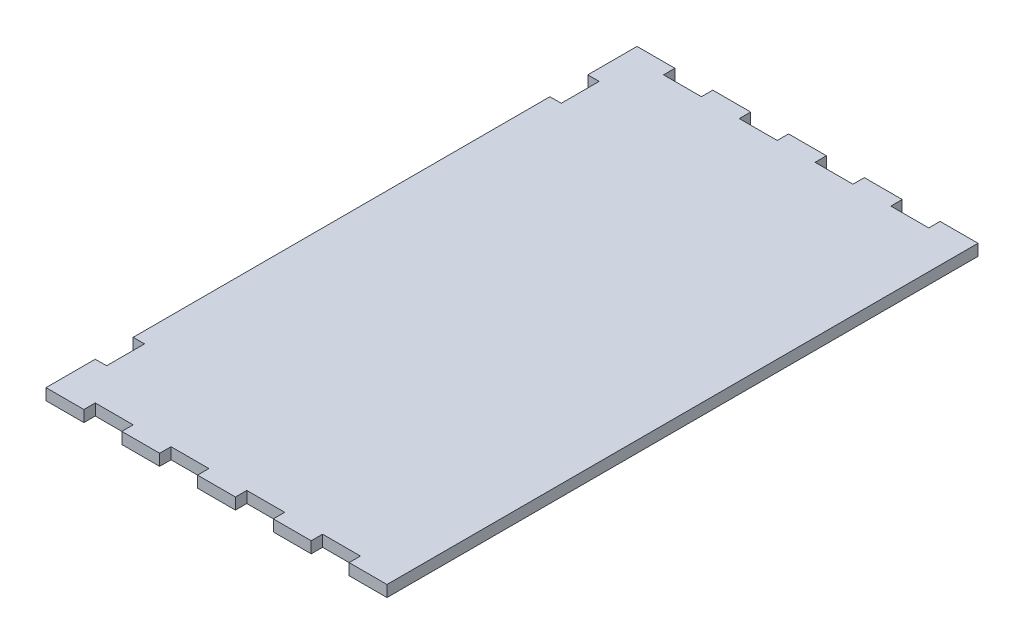
from build123d import *

# Parameters (mm, degrees)
BOSS_EXTRU_1_DEPTH = 3


with BuildPart() as part:
    # Esquisse1 → Boss.-Extru.1 (new body)
    with BuildSketch(Plane(origin=(0, 0, 0), x_dir=(1, 0, 0), z_dir=(0, 1, 0))):
        Polygon((-2.118354979, 8.128356032), (-2.118354979, 11.128356032), (-12.118354979, 11.128356032), (-12.118354979, 8.128356032), (-22.118354979, 8.128356032), (-22.118354979, 11.128356032), (-32.118354979, 11.128356032), (-32.118354979, -1.871643968), (-29.118354979, -1.871643968), (-29.118354979, -11.871643968), (-32.118354979, -11.871643968), (-32.118354979, -121.871643968), (-29.118354979, -121.871643968), (-29.118354979, -131.871643968), (-32.118354979, -131.871643968), (-32.118354979, -144.871643968), (-22.118354979, -144.871643968), (-22.118354979, -141.871643968), (-12.118354979, -141.871643968), (-12.118354979, -144.871643968), (-2.118354979, -144.871643968), (-2.118354979, -141.871643968), (7.881645021, -141.871643968), (7.881645021, -144.871643968), (17.881645021, -144.871643968), (17.881645021, -141.871643968), (27.881645021, -141.871643968), (27.881645021, -144.871643968), (37.881645021, -144.871643968), (37.881645021, -141.871643968), (47.881645021, -141.871643968), (47.881645021, -144.871643968), (57.881645021, -144.871643968), (57.881645021, 11.128356032), (47.881645021, 11.128356032), (47.881645021, 8.128356032), (37.881645021, 8.128356032), (37.881645021, 11.128356032), (27.881645021, 11.128356032), (27.881645021, 8.128356032), (17.881645021, 8.128356032), (17.881645021, 11.128356032), (7.881645021, 11.128356032), (7.881645021, 8.128356032), align=None)
    extrude(amount=BOSS_EXTRU_1_DEPTH)


solid = part.part
